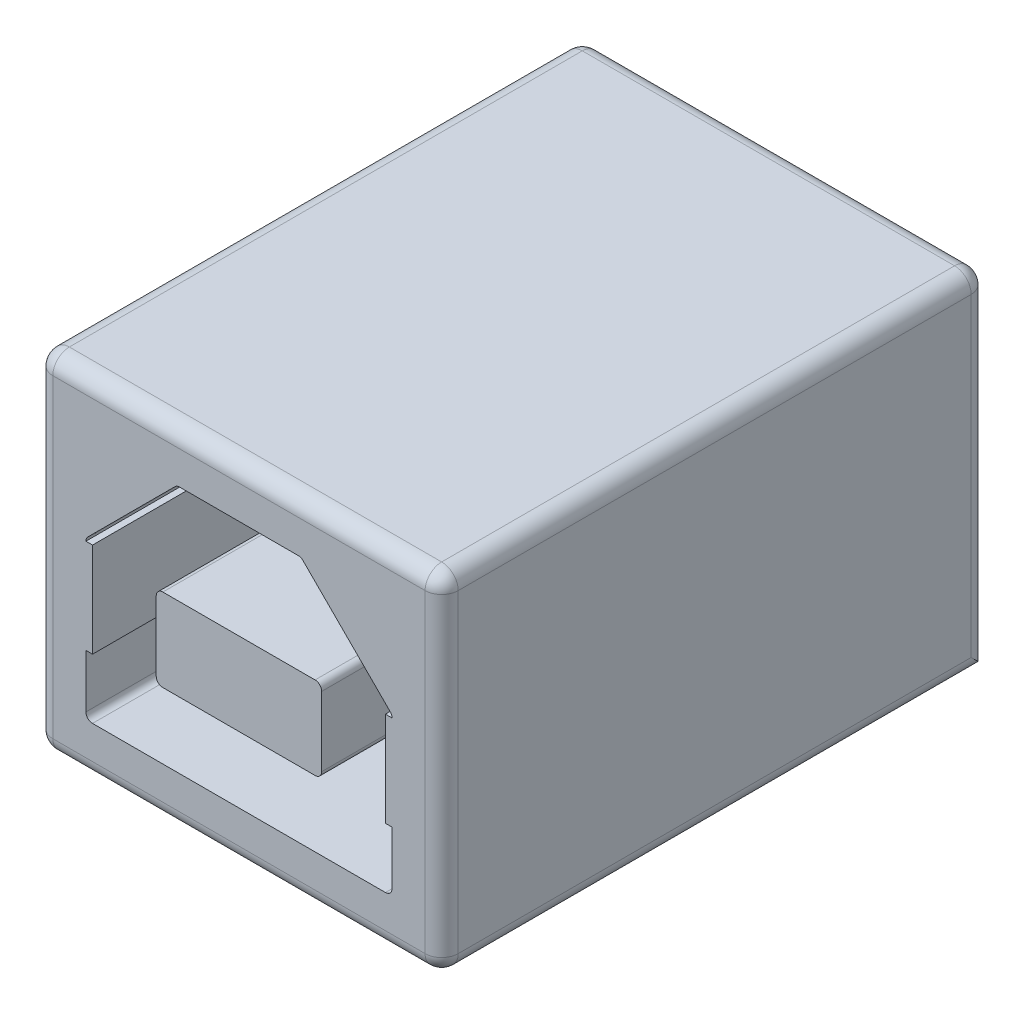
from build123d import *

# Parameters (mm, degrees)
SKETCH1_W           = 12.25
SKETCH1_H           = 10.5
BOSS_EXTRUDE1_DEPTH = 16.5
CUT_EXTRUDE1_DEPTH  = 15
FILLET1_R           = 0.5
SKETCH8_W           = 7.057916012
SKETCH8_H           = 2.856354625
BOSS_EXTRUDE3_DEPTH = 0.2
SKETCH4_W           = 7.057916012
SKETCH4_H           = 2.856354625
BOSS_EXTRUDE4_DEPTH = 0.2


with BuildPart() as part:
    # Sketch1 → Boss-Extrude1 (new body)
    with BuildSketch(Plane.XY):
        with Locations((6.125, 5.25)):
            Rectangle(SKETCH1_W, SKETCH1_H)
    extrude(amount=-BOSS_EXTRUDE1_DEPTH)

    # Sketch3 → Cut-Extrude1 (cut)
    with BuildSketch(Plane.XY):
        with BuildLine():
            Line((1.5, 6.167157288), (1.5, 1.7))
            ThreePointArc((1.5, 1.7), (1.558578644, 1.558578644), (1.7, 1.5))
            Line((1.7, 1.5), (10.55, 1.5))
            ThreePointArc((10.55, 1.5), (10.691421356, 1.558578644), (10.75, 1.7))
            Line((10.75, 1.7), (10.75, 6.167157288))
            ThreePointArc((10.75, 6.167157288), (10.734775907, 6.243693974), (10.691421356, 6.308578644))
            Line((10.691421356, 6.308578644), (8.058578644, 8.941421356))
            ThreePointArc((8.058578644, 8.941421356), (7.993693974, 8.984775907), (7.917157288, 9))
            Line((7.917157288, 9), (4.332842712, 9))
            ThreePointArc((4.332842712, 9), (4.256306026, 8.984775907), (4.191421356, 8.941421356))
            Line((4.191421356, 8.941421356), (1.558578644, 6.308578644))
            ThreePointArc((1.558578644, 6.308578644), (1.515224093, 6.243693974), (1.5, 6.167157288))
        make_face()
        with BuildLine():
            ThreePointArc((3.825, 6), (3.683578644, 5.941421356), (3.625, 5.8))
            Line((3.625, 5.8), (3.625, 3.7))
            ThreePointArc((3.625, 3.7), (3.683578644, 3.558578644), (3.825, 3.5))
            Line((3.825, 3.5), (8.425, 3.5))
            ThreePointArc((8.425, 3.5), (8.566421356, 3.558578644), (8.625, 3.7))
            Line((8.625, 3.7), (8.625, 5.8))
            ThreePointArc((8.625, 5.8), (8.566421356, 5.941421356), (8.425, 6))
            Line((8.425, 6), (3.825, 6))
        make_face(mode=Mode.SUBTRACT)
    extrude(amount=-CUT_EXTRUDE1_DEPTH, mode=Mode.SUBTRACT)

    # Fillet1
    fillet1_edges = [part.edges().sort_by_distance(p)[0] for p in [
        (12.25, 5.25, -16.5),
        (6.125, 10.5, -16.5),
        (8.625, 4.75, -15),
        (8.566421356, 5.941421356, -15),
        (6.125, 6, -15),
        (3.683578644, 5.941421356, -15),
        (3.625, 4.75, -15),
        (3.683578644, 3.558578644, -15),
        (6.125, 3.5, -15),
        (8.566421356, 3.558578644, -15),
        (0, 5.25, -16.5),
        (6.125, 10.5, 0),
        (12.25, 5.25, 0),
        (6.125, 0, 0),
        (0, 5.25, 0),
        (0, 10.5, -8.25),
        (12.25, 10.5, -8.25),
        (12.25, 0, -8.25),
        (0, 0, -8.25),
    ]]
    fillet(fillet1_edges, radius=FILLET1_R)

    # Sketch8 → Boss-Extrude3 (add)
    with BuildSketch(Plane(origin=(1.5, 0, 0), x_dir=(0, 0, -1), z_dir=(1, 0, 0))):
        with Locations((3.528958006, 4.738979976)):
            Rectangle(SKETCH8_W, SKETCH8_H)
    extrude(amount=BOSS_EXTRUDE3_DEPTH)

    # Sketch4 → Boss-Extrude4 (add)
    with BuildSketch(Plane.ZY.offset(-10.75)):
        with Locations((-3.528958006, 4.738979976)):
            Rectangle(SKETCH4_W, SKETCH4_H)
    extrude(amount=BOSS_EXTRUDE4_DEPTH)


solid = part.part
